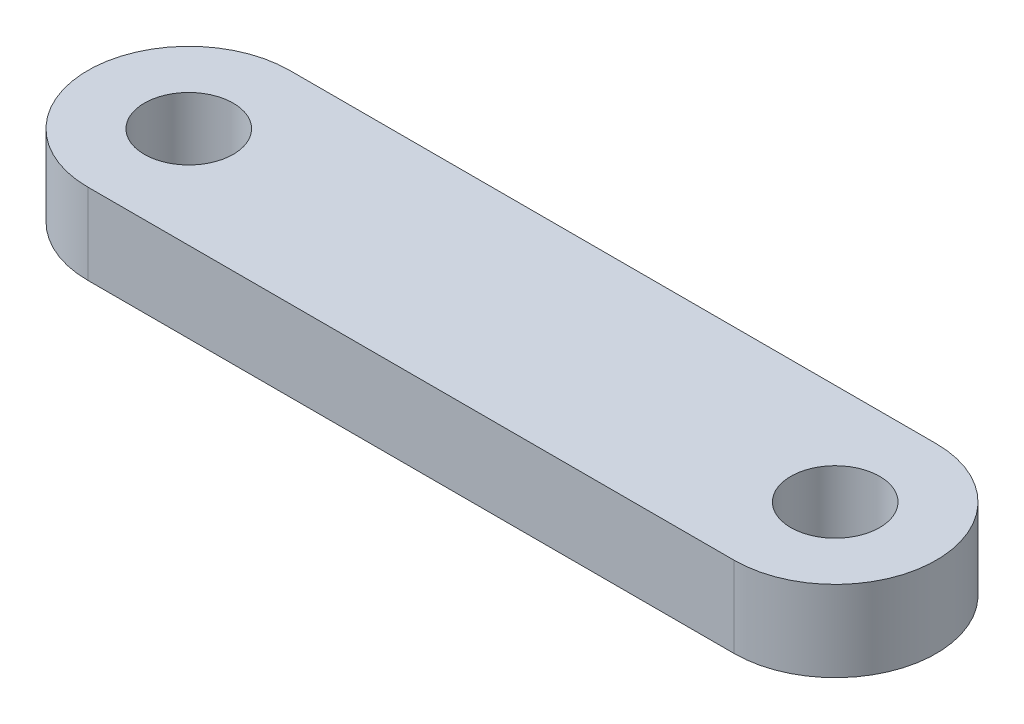
from build123d import *

# Parameters (mm, degrees)
SKETCH1_R           = 1.1
BOSS_EXTRUDE1_DEPTH = 2


with BuildPart() as part:
    # Sketch1 → Boss-Extrude1 (new body)
    with BuildSketch(Plane(origin=(0, 0, 0), x_dir=(1, 0, 0), z_dir=(0, 1, 0))):
        with BuildLine():
            Line((0, 2.5), (16, 2.5))
            ThreePointArc((16, 2.5), (18.5, 0), (16, -2.5))
            Line((16, -2.5), (0, -2.5))
            ThreePointArc((0, -2.5), (-2.5, 0), (0, 2.5))
        make_face()
        Circle(SKETCH1_R, mode=Mode.SUBTRACT)
        with Locations((16, 0)):
            Circle(SKETCH1_R, mode=Mode.SUBTRACT)
    extrude(amount=BOSS_EXTRUDE1_DEPTH)


solid = part.part
